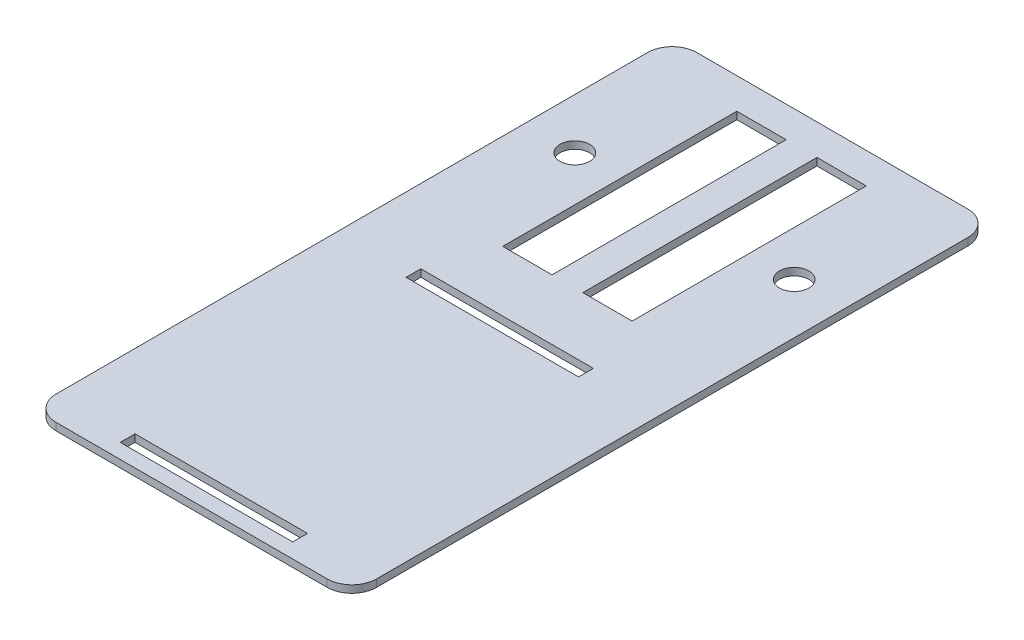
from build123d import *

# Parameters (mm, degrees)
SKETCH1_W               = 130
SKETCH1_H               = 120
BOSS_EXTRUDE1_DEPTH     = 3
CUT_EXTRUDE1_START      = -4
SKETCH2_W               = 20
SKETCH2_H               = 95
CUT_EXTRUDE1_DEPTH      = 5
CUT_EXTRUDE2_START      = -4
SKETCH3_R               = 6
CUT_EXTRUDE2_DEPTH      = 5
SKETCH4_W               = 130
SKETCH4_H               = 3
BOSS_EXTRUDE2_DEPTH     = 140
SKETCH5_W               = 70
SKETCH5_H               = 6
CUT_EXTRUDE3_DEPTH      = 1
CUT_EXTRUDE3_DEPTH_BACK = 4
FILLET1_R               = 10


with BuildPart() as part:
    # Sketch1 → Boss-Extrude1 (new body)
    with BuildSketch(Plane(origin=(0, 0, 0), x_dir=(1, 0, 0), z_dir=(0, 1, 0))):
        Rectangle(SKETCH1_W, SKETCH1_H)
    extrude(amount=BOSS_EXTRUDE1_DEPTH)

    # Sketch2 → Cut-Extrude1 (cut)
    with BuildSketch(Plane(origin=(0, 3, 0), x_dir=(1, 0, 0), z_dir=(0, 1, 0)).offset(CUT_EXTRUDE1_START)):
        with Locations((-16.25, 0)):
            Rectangle(SKETCH2_W, SKETCH2_H)
    cut_extrude1 = extrude(amount=CUT_EXTRUDE1_DEPTH, mode=Mode.SUBTRACT)

    # Mirror1: Cut-Extrude1 across plane
    add(cut_extrude1.mirror(Plane(origin=(0, 0, 0), x_dir=(0, 0, 1), z_dir=(1, 0, 0))), mode=Mode.SUBTRACT)

    # Sketch3 → Cut-Extrude2 (cut)
    with BuildSketch(Plane(origin=(0, 3, 0), x_dir=(1, 0, 0), z_dir=(0, 1, 0)).offset(CUT_EXTRUDE2_START)):
        with Locations((44.5, 0)):
            Circle(SKETCH3_R)
    cut_extrude2 = extrude(amount=CUT_EXTRUDE2_DEPTH, mode=Mode.SUBTRACT)

    # Mirror2: Cut-Extrude2 across plane
    add(cut_extrude2.mirror(Plane(origin=(0, 0, 0), x_dir=(0, 0, 1), z_dir=(1, 0, 0))), mode=Mode.SUBTRACT)

    # Sketch4 → Boss-Extrude2 (add)
    with BuildSketch(Plane.XY.offset(60)):
        with Locations((0, 1.5)):
            Rectangle(SKETCH4_W, SKETCH4_H)
    extrude(amount=BOSS_EXTRUDE2_DEPTH)

    # Sketch5 → Cut-Extrude3 (cut, two sides)
    with BuildSketch(Plane(origin=(0, 3, 0), x_dir=(1, 0, 0), z_dir=(0, 1, 0))) as cut_extrude3_sk:
        with Locations((0, -75)):
            Rectangle(SKETCH5_W, SKETCH5_H)
        with Locations((0, -191)):
            Rectangle(SKETCH5_W, SKETCH5_H)
    extrude(amount=CUT_EXTRUDE3_DEPTH, mode=Mode.SUBTRACT)
    extrude(cut_extrude3_sk.sketch, amount=-CUT_EXTRUDE3_DEPTH_BACK, mode=Mode.SUBTRACT)

    # Fillet1
    fillet1_edges = [part.edges().sort_by_distance(p)[0] for p in [
        (-65, 1.5, 200),
        (65, 1.5, 200),
        (-65, 1.5, -60),
        (65, 1.5, -60),
    ]]
    fillet(fillet1_edges, radius=FILLET1_R)


solid = part.part
